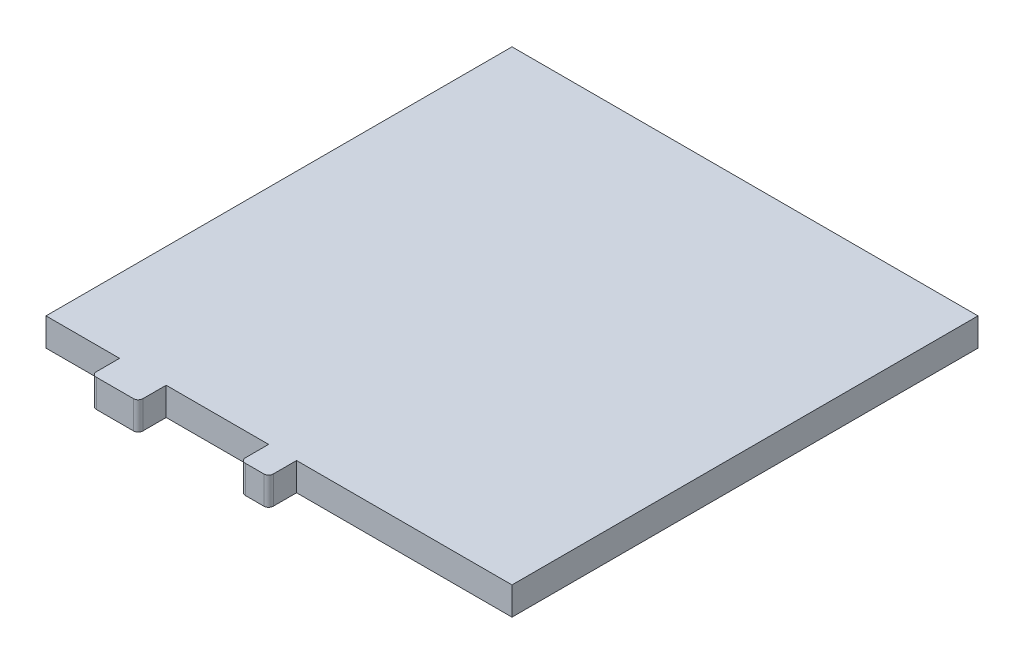
from build123d import *

# Parameters (mm, degrees)
SKETCH1_W              = 100
SKETCH1_H              = 100
BOSS_EXTRUDE1_DEPTH    = 6
SKETCH234_W            = 6
SKETCH234_H            = 6
BOSS_EXTRUDE234_DEPTH  = 6
FILLET134_R            = 1
SKETCH2342_W           = 10
SKETCH2342_H           = 6
BOSS_EXTRUDE2342_DEPTH = 6
FILLET1342_R           = 1


with BuildPart() as part:
    # Sketch1 → Boss-Extrude1 (new body)
    with BuildSketch(Plane(origin=(0, 0, 0), x_dir=(1, 0, 0), z_dir=(0, 1, 0))):
        Rectangle(SKETCH1_W, SKETCH1_H)
    extrude(amount=BOSS_EXTRUDE1_DEPTH)

    # Sketch234 → Boss-Extrude234 (add)
    with BuildSketch(Plane.XY.offset(50)):
        with Locations((0.767778608, 3)):
            Rectangle(SKETCH234_W, SKETCH234_H)
    extrude(amount=BOSS_EXTRUDE234_DEPTH)

    # Fillet134
    fillet134_edges = [part.edges().sort_by_distance(p)[0] for p in [
        (-2.232221392, 3, 56),
        (3.767778608, 3, 56),
    ]]
    fillet(fillet134_edges, radius=FILLET134_R)

    # Sketch2342 → Boss-Extrude2342 (add)
    with BuildSketch(Plane(origin=(-28.445435161, 6, 50), x_dir=(-1, 0, 0), z_dir=(0, 0, 1))):
        with Locations((0.767778608, 3)):
            Rectangle(SKETCH2342_W, SKETCH2342_H)
    extrude(amount=BOSS_EXTRUDE2342_DEPTH)

    # Fillet1342
    fillet1342_edges = [part.edges().sort_by_distance(p)[0] for p in [
        (-34.213213769, 3, 56),
        (-24.213213769, 3, 56),
    ]]
    fillet(fillet1342_edges, radius=FILLET1342_R)


solid = part.part
